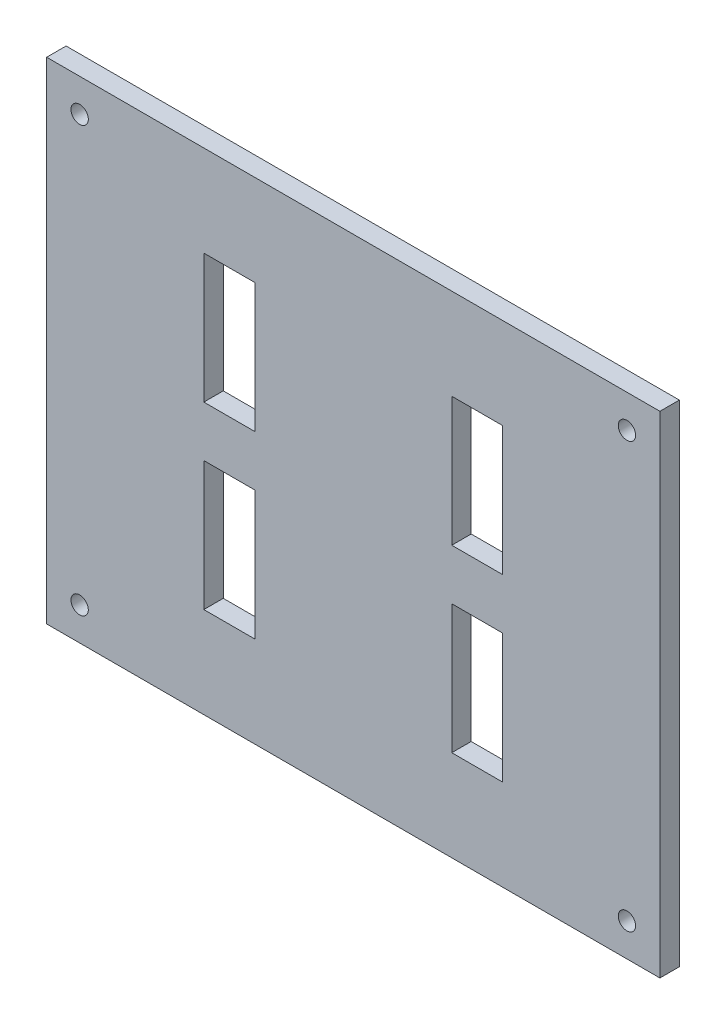
from build123d import *

# Parameters (mm, degrees)
SKETCH1_W           = 100.17
SKETCH1_H           = 80.17
BOSS_EXTRUDE1_DEPTH = 3.175
SKETCH3_R           = 1.415
CUT_EXTRUDE2_DEPTH  = 4.175
SKETCH2_W           = 8.33
SKETCH2_H           = 21.08
CUT_EXTRUDE3_DEPTH  = 10


with BuildPart() as part:
    # Sketch1 → Boss-Extrude1 (new body)
    with BuildSketch(Plane.XY):
        Rectangle(SKETCH1_W, SKETCH1_H)
    extrude(amount=BOSS_EXTRUDE1_DEPTH)

    # Sketch3 → Cut-Extrude2 (cut, through all)
    with BuildSketch(Plane.XY.offset(3.175)):
        with Locations((-44.696699141, 34.696699141)):
            Circle(SKETCH3_R)
        with Locations((44.696699141, 34.696699141)):
            Circle(SKETCH3_R)
        with Locations((44.696699141, -34.696699141)):
            Circle(SKETCH3_R)
        with Locations((-44.696699141, -34.696699141)):
            Circle(SKETCH3_R)
    extrude(amount=-CUT_EXTRUDE2_DEPTH, mode=Mode.SUBTRACT)

    # Sketch2 → Cut-Extrude3 (cut)
    with BuildSketch(Plane.XY.offset(3.175)):
        with Locations((-20.25, 14.675)):
            Rectangle(SKETCH2_W, SKETCH2_H)
        with Locations((20.25, 14.675)):
            Rectangle(SKETCH2_W, SKETCH2_H)
        with Locations((-20.25, -14.675)):
            Rectangle(SKETCH2_W, SKETCH2_H)
        with Locations((20.25, -14.675)):
            Rectangle(SKETCH2_W, SKETCH2_H)
    extrude(amount=-CUT_EXTRUDE3_DEPTH, mode=Mode.SUBTRACT)


solid = part.part
